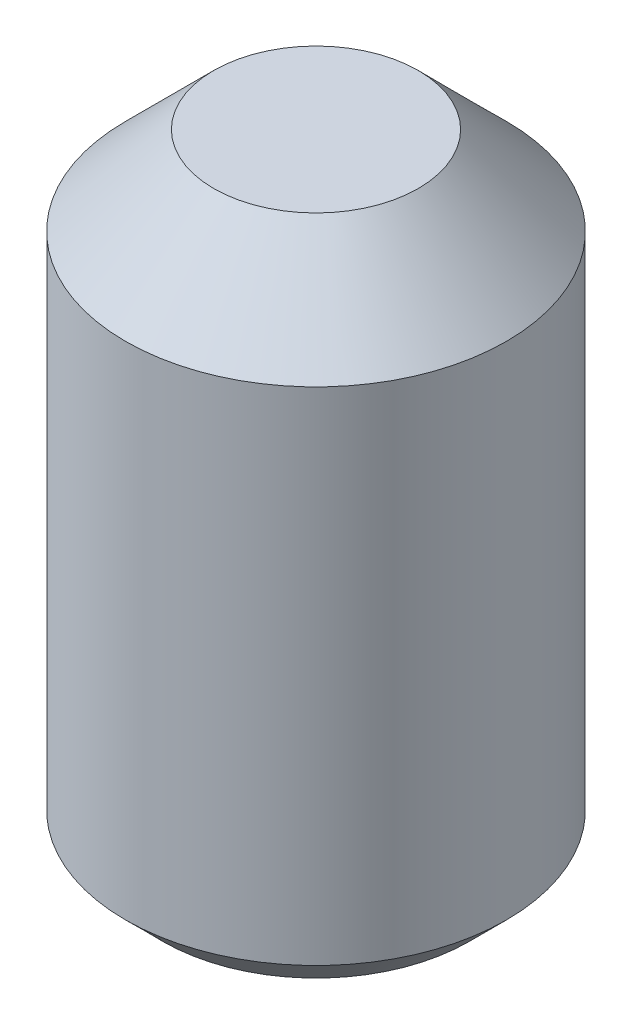
from build123d import *

# Parameters (mm, degrees)
CUT_EXTRUDE1_DEPTH = 2.54
CHAMFER1_SIZE      = 0.47244


with BuildPart() as part:
    # Sketch1 → Revolve1 (revolve)
    with BuildSketch(Plane(origin=(0, 0, 0), x_dir=(-1, 0, 0), z_dir=(0, 0, -1))):
        Polygon((-2.413, 0), (0, 0), (0, 7.9375), (-1.2954, 7.9375), (-2.413, 6.8199), align=None)
    revolve(axis=Axis((0, 0, 0), (0, 1, 0)))

    # Sketch2 → Cut-Extrude1 (cut)
    with BuildSketch(Plane.XZ):
        Polygon((-0.68704079, 1.189989555), (-1.37408158, 0), (-0.68704079, -1.189989555), (0.68704079, -1.189989555), (1.37408158, 0), (0.68704079, 1.189989555), align=None)
    extrude(amount=-CUT_EXTRUDE1_DEPTH, mode=Mode.SUBTRACT)

    # Chamfer1
    chamfer1_edges = [part.edges().sort_by_distance(p)[0] for p in [
        (-2.413, 0, 0),
    ]]
    chamfer(chamfer1_edges, length=CHAMFER1_SIZE)


solid = part.part
